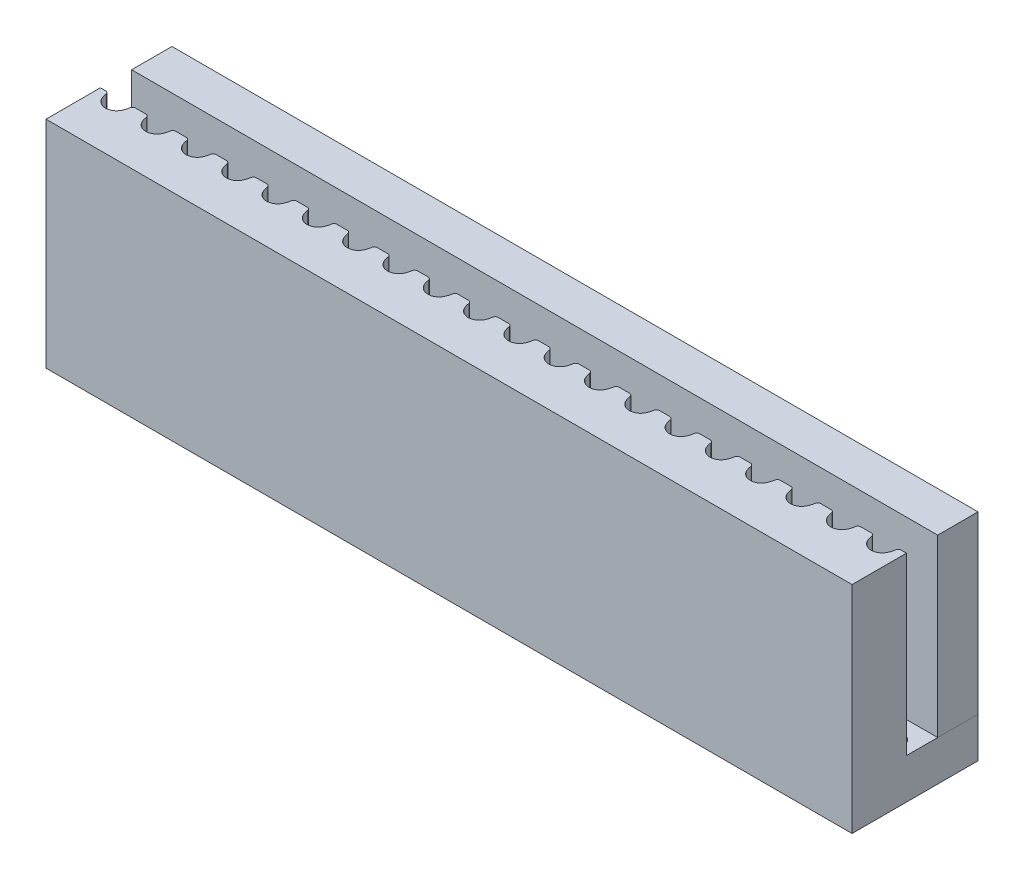
from build123d import *

# Parameters (mm, degrees)
BOSS_EXTRUDE1_DEPTH   = 8.7
SKETCH1_W             = 40
SKETCH1_H             = 2
BOSS_EXTRUDE1_2_DEPTH = 8.7
SKETCH2_W             = 40
SKETCH2_H             = 6.25
SKETCH2_R             = 0.5
BOSS_EXTRUDE2_DEPTH   = 2


with BuildPart() as part:
    # Sketch1 → Boss-Extrude1 (new body)
    with BuildSketch(Plane(origin=(0, 0, 0), x_dir=(1, 0, 0), z_dir=(0, 1, 0))):
        with BuildLine():
            Line((-19.740175425, 0.32), (-20, 0.32))
            Line((-20, 0.32), (-20, -2.38))
            Line((-20, -2.38), (20, -2.38))
            Line((20, -2.38), (20, 0.32))
            Line((20, 0.32), (19.740175425, 0.32))
            ThreePointArc((19.740175425, 0.32), (19.641268354, 0.282771412), (19.591456891, 0.189565217))
            ThreePointArc((19.591456891, 0.189565217), (19.557611714, 0.031937846), (19.498876404, -0.118202247))
            ThreePointArc((19.498876404, -0.118202247), (19, -0.43), (18.501123596, -0.118202247))
            ThreePointArc((18.501123596, -0.118202247), (18.442388286, 0.031937846), (18.408543109, 0.189565217))
            ThreePointArc((18.408543109, 0.189565217), (18.358731646, 0.282771412), (18.259824575, 0.32))
            Line((18.259824575, 0.32), (17.740175425, 0.32))
            ThreePointArc((17.740175425, 0.32), (17.641268354, 0.282771412), (17.591456891, 0.189565217))
            ThreePointArc((17.591456891, 0.189565217), (17.557611714, 0.031937846), (17.498876404, -0.118202247))
            ThreePointArc((17.498876404, -0.118202247), (17, -0.43), (16.501123596, -0.118202247))
            ThreePointArc((16.501123596, -0.118202247), (16.442388286, 0.031937846), (16.408543109, 0.189565217))
            ThreePointArc((16.408543109, 0.189565217), (16.358731646, 0.282771412), (16.259824575, 0.32))
            Line((16.259824575, 0.32), (15.740175425, 0.32))
            ThreePointArc((15.740175425, 0.32), (15.641268354, 0.282771412), (15.591456891, 0.189565217))
            ThreePointArc((15.591456891, 0.189565217), (15.557611714, 0.031937846), (15.498876404, -0.118202247))
            ThreePointArc((15.498876404, -0.118202247), (15, -0.43), (14.501123596, -0.118202247))
            ThreePointArc((14.501123596, -0.118202247), (14.442388286, 0.031937846), (14.408543109, 0.189565217))
            ThreePointArc((14.408543109, 0.189565217), (14.358731646, 0.282771412), (14.259824575, 0.32))
            Line((14.259824575, 0.32), (13.740175425, 0.32))
            ThreePointArc((13.740175425, 0.32), (13.641268354, 0.282771412), (13.591456891, 0.189565217))
            ThreePointArc((13.591456891, 0.189565217), (13.557611714, 0.031937846), (13.498876404, -0.118202247))
            ThreePointArc((13.498876404, -0.118202247), (13, -0.43), (12.501123596, -0.118202247))
            ThreePointArc((12.501123596, -0.118202247), (12.442388286, 0.031937846), (12.408543109, 0.189565217))
            ThreePointArc((12.408543109, 0.189565217), (12.358731646, 0.282771412), (12.259824575, 0.32))
            Line((12.259824575, 0.32), (11.740175425, 0.32))
            ThreePointArc((11.740175425, 0.32), (11.641268354, 0.282771412), (11.591456891, 0.189565217))
            ThreePointArc((11.591456891, 0.189565217), (11.557611714, 0.031937846), (11.498876404, -0.118202247))
            ThreePointArc((11.498876404, -0.118202247), (11, -0.43), (10.501123596, -0.118202247))
            ThreePointArc((10.501123596, -0.118202247), (10.442388286, 0.031937846), (10.408543109, 0.189565217))
            ThreePointArc((10.408543109, 0.189565217), (10.358731646, 0.282771412), (10.259824575, 0.32))
            Line((10.259824575, 0.32), (9.740175425, 0.32))
            ThreePointArc((9.740175425, 0.32), (9.641268354, 0.282771412), (9.591456891, 0.189565217))
            ThreePointArc((9.591456891, 0.189565217), (9.557611714, 0.031937846), (9.498876404, -0.118202247))
            ThreePointArc((9.498876404, -0.118202247), (9, -0.43), (8.501123596, -0.118202247))
            ThreePointArc((8.501123596, -0.118202247), (8.442388286, 0.031937846), (8.408543109, 0.189565217))
            ThreePointArc((8.408543109, 0.189565217), (8.358731646, 0.282771412), (8.259824575, 0.32))
            Line((8.259824575, 0.32), (7.740175425, 0.32))
            ThreePointArc((7.740175425, 0.32), (7.641268354, 0.282771412), (7.591456891, 0.189565217))
            ThreePointArc((7.591456891, 0.189565217), (7.557611714, 0.031937846), (7.498876404, -0.118202247))
            ThreePointArc((7.498876404, -0.118202247), (7, -0.43), (6.501123596, -0.118202247))
            ThreePointArc((6.501123596, -0.118202247), (6.442388286, 0.031937846), (6.408543109, 0.189565217))
            ThreePointArc((6.408543109, 0.189565217), (6.358731646, 0.282771412), (6.259824575, 0.32))
            Line((6.259824575, 0.32), (5.740175425, 0.32))
            ThreePointArc((5.740175425, 0.32), (5.641268354, 0.282771412), (5.591456891, 0.189565217))
            ThreePointArc((5.591456891, 0.189565217), (5.557611714, 0.031937846), (5.498876404, -0.118202247))
            ThreePointArc((5.498876404, -0.118202247), (5, -0.43), (4.501123596, -0.118202247))
            ThreePointArc((4.501123596, -0.118202247), (4.442388286, 0.031937846), (4.408543109, 0.189565217))
            ThreePointArc((4.408543109, 0.189565217), (4.358731646, 0.282771412), (4.259824575, 0.32))
            Line((4.259824575, 0.32), (3.740175425, 0.32))
            ThreePointArc((3.740175425, 0.32), (3.641268354, 0.282771412), (3.591456891, 0.189565217))
            ThreePointArc((3.591456891, 0.189565217), (3.557611714, 0.031937846), (3.498876404, -0.118202247))
            ThreePointArc((3.498876404, -0.118202247), (3, -0.43), (2.501123596, -0.118202247))
            ThreePointArc((2.501123596, -0.118202247), (2.442388286, 0.031937846), (2.408543109, 0.189565217))
            ThreePointArc((2.408543109, 0.189565217), (2.358731646, 0.282771412), (2.259824575, 0.32))
            Line((2.259824575, 0.32), (1.740175425, 0.32))
            ThreePointArc((1.740175425, 0.32), (1.641268354, 0.282771412), (1.591456891, 0.189565217))
            ThreePointArc((1.591456891, 0.189565217), (1.557611714, 0.031937846), (1.498876404, -0.118202247))
            ThreePointArc((1.498876404, -0.118202247), (1, -0.43), (0.501123596, -0.118202247))
            ThreePointArc((0.501123596, -0.118202247), (0.442388286, 0.031937846), (0.408543109, 0.189565217))
            ThreePointArc((0.408543109, 0.189565217), (0.358731646, 0.282771412), (0.259824575, 0.32))
            Line((0.259824575, 0.32), (-0.259824575, 0.32))
            ThreePointArc((-0.259824575, 0.32), (-0.358731646, 0.282771412), (-0.408543109, 0.189565217))
            ThreePointArc((-0.408543109, 0.189565217), (-0.442388286, 0.031937846), (-0.501123596, -0.118202247))
            ThreePointArc((-0.501123596, -0.118202247), (-1, -0.43), (-1.498876404, -0.118202247))
            ThreePointArc((-1.498876404, -0.118202247), (-1.557611714, 0.031937846), (-1.591456891, 0.189565217))
            ThreePointArc((-1.591456891, 0.189565217), (-1.641268354, 0.282771412), (-1.740175425, 0.32))
            Line((-1.740175425, 0.32), (-2.259824575, 0.32))
            ThreePointArc((-2.259824575, 0.32), (-2.358731646, 0.282771412), (-2.408543109, 0.189565217))
            ThreePointArc((-2.408543109, 0.189565217), (-2.442388286, 0.031937846), (-2.501123596, -0.118202247))
            ThreePointArc((-2.501123596, -0.118202247), (-3, -0.43), (-3.498876404, -0.118202247))
            ThreePointArc((-3.498876404, -0.118202247), (-3.557611714, 0.031937846), (-3.591456891, 0.189565217))
            ThreePointArc((-3.591456891, 0.189565217), (-3.641268354, 0.282771412), (-3.740175425, 0.32))
            Line((-3.740175425, 0.32), (-4.259824575, 0.32))
            ThreePointArc((-4.259824575, 0.32), (-4.358731646, 0.282771412), (-4.408543109, 0.189565217))
            ThreePointArc((-4.408543109, 0.189565217), (-4.442388286, 0.031937846), (-4.501123596, -0.118202247))
            ThreePointArc((-4.501123596, -0.118202247), (-5, -0.43), (-5.498876404, -0.118202247))
            ThreePointArc((-5.498876404, -0.118202247), (-5.557611714, 0.031937846), (-5.591456891, 0.189565217))
            ThreePointArc((-5.591456891, 0.189565217), (-5.641268354, 0.282771412), (-5.740175425, 0.32))
            Line((-5.740175425, 0.32), (-6.259824575, 0.32))
            ThreePointArc((-6.259824575, 0.32), (-6.358731646, 0.282771412), (-6.408543109, 0.189565217))
            ThreePointArc((-6.408543109, 0.189565217), (-6.442388286, 0.031937846), (-6.501123596, -0.118202247))
            ThreePointArc((-6.501123596, -0.118202247), (-7, -0.43), (-7.498876404, -0.118202247))
            ThreePointArc((-7.498876404, -0.118202247), (-7.557611714, 0.031937846), (-7.591456891, 0.189565217))
            ThreePointArc((-7.591456891, 0.189565217), (-7.641268354, 0.282771412), (-7.740175425, 0.32))
            Line((-7.740175425, 0.32), (-8.259824575, 0.32))
            ThreePointArc((-8.259824575, 0.32), (-8.358731646, 0.282771412), (-8.408543109, 0.189565217))
            ThreePointArc((-8.408543109, 0.189565217), (-8.442388286, 0.031937846), (-8.501123596, -0.118202247))
            ThreePointArc((-8.501123596, -0.118202247), (-9, -0.43), (-9.498876404, -0.118202247))
            ThreePointArc((-9.498876404, -0.118202247), (-9.557611714, 0.031937846), (-9.591456891, 0.189565217))
            ThreePointArc((-9.591456891, 0.189565217), (-9.641268354, 0.282771412), (-9.740175425, 0.32))
            Line((-9.740175425, 0.32), (-10.259824575, 0.32))
            ThreePointArc((-10.259824575, 0.32), (-10.358731646, 0.282771412), (-10.408543109, 0.189565217))
            ThreePointArc((-10.408543109, 0.189565217), (-10.442388286, 0.031937846), (-10.501123596, -0.118202247))
            ThreePointArc((-10.501123596, -0.118202247), (-11, -0.43), (-11.498876404, -0.118202247))
            ThreePointArc((-11.498876404, -0.118202247), (-11.557611714, 0.031937846), (-11.591456891, 0.189565217))
            ThreePointArc((-11.591456891, 0.189565217), (-11.641268354, 0.282771412), (-11.740175425, 0.32))
            Line((-11.740175425, 0.32), (-12.259824575, 0.32))
            ThreePointArc((-12.259824575, 0.32), (-12.358731646, 0.282771412), (-12.408543109, 0.189565217))
            ThreePointArc((-12.408543109, 0.189565217), (-12.442388286, 0.031937846), (-12.501123596, -0.118202247))
            ThreePointArc((-12.501123596, -0.118202247), (-13, -0.43), (-13.498876404, -0.118202247))
            ThreePointArc((-13.498876404, -0.118202247), (-13.557611714, 0.031937846), (-13.591456891, 0.189565217))
            ThreePointArc((-13.591456891, 0.189565217), (-13.641268354, 0.282771412), (-13.740175425, 0.32))
            Line((-13.740175425, 0.32), (-14.259824575, 0.32))
            ThreePointArc((-14.259824575, 0.32), (-14.358731646, 0.282771412), (-14.408543109, 0.189565217))
            ThreePointArc((-14.408543109, 0.189565217), (-14.442388286, 0.031937846), (-14.501123596, -0.118202247))
            ThreePointArc((-14.501123596, -0.118202247), (-15, -0.43), (-15.498876404, -0.118202247))
            ThreePointArc((-15.498876404, -0.118202247), (-15.557611714, 0.031937846), (-15.591456891, 0.189565217))
            ThreePointArc((-15.591456891, 0.189565217), (-15.641268354, 0.282771412), (-15.740175425, 0.32))
            Line((-15.740175425, 0.32), (-16.259824575, 0.32))
            ThreePointArc((-16.259824575, 0.32), (-16.358731646, 0.282771412), (-16.408543109, 0.189565217))
            ThreePointArc((-16.408543109, 0.189565217), (-16.442388286, 0.031937846), (-16.501123596, -0.118202247))
            ThreePointArc((-16.501123596, -0.118202247), (-17, -0.43), (-17.498876404, -0.118202247))
            ThreePointArc((-17.498876404, -0.118202247), (-17.557611714, 0.031937846), (-17.591456891, 0.189565217))
            ThreePointArc((-17.591456891, 0.189565217), (-17.641268354, 0.282771412), (-17.740175425, 0.32))
            Line((-17.740175425, 0.32), (-18.259824575, 0.32))
            ThreePointArc((-18.259824575, 0.32), (-18.358731646, 0.282771412), (-18.408543109, 0.189565217))
            ThreePointArc((-18.408543109, 0.189565217), (-18.442388286, 0.031937846), (-18.501123596, -0.118202247))
            ThreePointArc((-18.501123596, -0.118202247), (-19, -0.43), (-19.498876404, -0.118202247))
            ThreePointArc((-19.498876404, -0.118202247), (-19.557611714, 0.031937846), (-19.591456891, 0.189565217))
            ThreePointArc((-19.591456891, 0.189565217), (-19.641268354, 0.282771412), (-19.740175425, 0.32))
        make_face()
    extrude(amount=BOSS_EXTRUDE1_DEPTH)

    # Sketch2 → Boss-Extrude2 (add)
    with BuildSketch(Plane.XZ):
        with Locations((0, -0.745)):
            Rectangle(SKETCH2_W, SKETCH2_H)
        with Locations((-19, -0.67)):
            Circle(SKETCH2_R, mode=Mode.SUBTRACT)
        with Locations((-17, -0.67)):
            Circle(SKETCH2_R, mode=Mode.SUBTRACT)
        with Locations((-15, -0.67)):
            Circle(SKETCH2_R, mode=Mode.SUBTRACT)
        with Locations((-13, -0.67)):
            Circle(SKETCH2_R, mode=Mode.SUBTRACT)
        with Locations((-11, -0.67)):
            Circle(SKETCH2_R, mode=Mode.SUBTRACT)
        with Locations((-9, -0.67)):
            Circle(SKETCH2_R, mode=Mode.SUBTRACT)
        with Locations((-7, -0.67)):
            Circle(SKETCH2_R, mode=Mode.SUBTRACT)
        with Locations((-5, -0.67)):
            Circle(SKETCH2_R, mode=Mode.SUBTRACT)
        with Locations((-3, -0.67)):
            Circle(SKETCH2_R, mode=Mode.SUBTRACT)
        with Locations((-1, -0.67)):
            Circle(SKETCH2_R, mode=Mode.SUBTRACT)
        with Locations((1, -0.67)):
            Circle(SKETCH2_R, mode=Mode.SUBTRACT)
        with Locations((3, -0.67)):
            Circle(SKETCH2_R, mode=Mode.SUBTRACT)
        with Locations((5, -0.67)):
            Circle(SKETCH2_R, mode=Mode.SUBTRACT)
        with Locations((7, -0.67)):
            Circle(SKETCH2_R, mode=Mode.SUBTRACT)
        with Locations((9, -0.67)):
            Circle(SKETCH2_R, mode=Mode.SUBTRACT)
        with Locations((11, -0.67)):
            Circle(SKETCH2_R, mode=Mode.SUBTRACT)
        with Locations((13, -0.67)):
            Circle(SKETCH2_R, mode=Mode.SUBTRACT)
        with Locations((15, -0.67)):
            Circle(SKETCH2_R, mode=Mode.SUBTRACT)
        with Locations((17, -0.67)):
            Circle(SKETCH2_R, mode=Mode.SUBTRACT)
        with Locations((19, -0.67)):
            Circle(SKETCH2_R, mode=Mode.SUBTRACT)
    extrude(amount=BOSS_EXTRUDE2_DEPTH)


with BuildPart() as body_2:
    # Sketch1 → Boss-Extrude1 2 (new body)
    with BuildSketch(Plane(origin=(0, 0, 0), x_dir=(1, 0, 0), z_dir=(0, 1, 0))):
        with Locations((0, 2.87)):
            Rectangle(SKETCH1_W, SKETCH1_H)
    extrude(amount=BOSS_EXTRUDE1_2_DEPTH)


solid = Compound([part.part, body_2.part])
